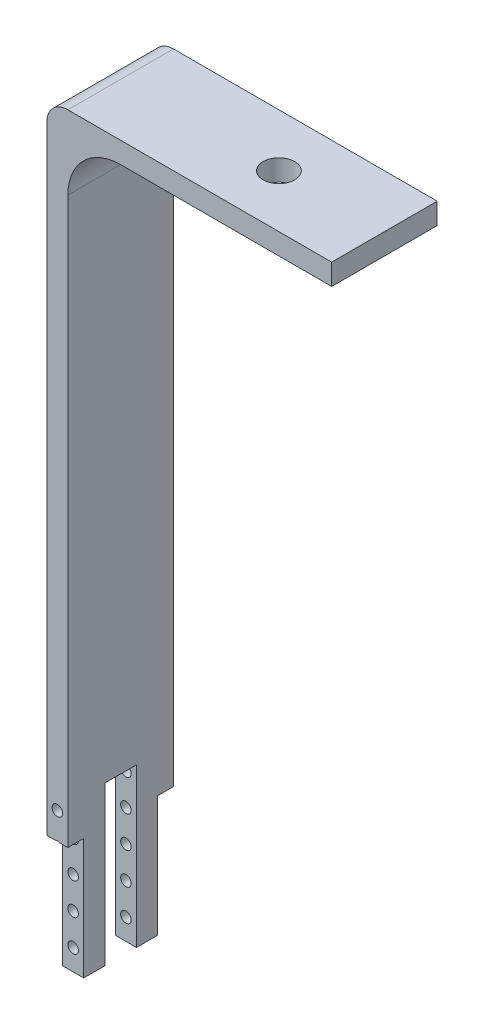
from build123d import *

# Parameters (mm, degrees)
Y_KSEKLIK_EKSTR_ZYON1_DEPTH = 10
IZIM2_W                     = 1.5
IZIM2_H                     = 11.454648232
IZIM2_W_2                   = 3
IZIM2_H_2                   = 15
KES_EKSTR_ZYON1_DEPTH       = 10
IZIM3_R                     = 0.5
KES_EKSTR_ZYON2_DEPTH       = 22
IZIM4_R                     = 1.5
KES_EKSTR_ZYON3_DEPTH       = 44
RADYUS1_R                   = 5
RADYUS2_R                   = 2


with BuildPart() as part:
    # Çizim1 → Yükseklik-Ekstrüzyon1 (new body)
    with BuildSketch(Plane.XY):
        Polygon((-4.798797212, 38.403805497), (-29.798797212, 38.403805497), (-29.798797212, -31.596194503), (-31.798797212, -31.596194503), (-31.798797212, 40.403805497), (-4.798797212, 40.403805497), align=None)
    extrude(amount=Y_KSEKLIK_EKSTR_ZYON1_DEPTH)

    # Çizim2 → Kes-Ekstrüzyon1 (cut)
    with BuildSketch(Plane(origin=(-29.798797212, 0, 0), x_dir=(0, 0, -1), z_dir=(1, 0, 0))):
        with Locations((-9.25, -25.868870387)):
            Rectangle(IZIM2_W, IZIM2_H)
        with Locations((-0.75, -25.868870387)):
            Rectangle(IZIM2_W, IZIM2_H)
        with Locations((-5, -24.096194503)):
            Rectangle(IZIM2_W_2, IZIM2_H_2)
    extrude(amount=-KES_EKSTR_ZYON1_DEPTH, mode=Mode.SUBTRACT)

    # Çizim3 → Kes-Ekstrüzyon2 (cut, symmetric)
    with BuildSketch(Plane.XY.offset(8.5)):
        with Locations((-30.798797212, -29.596194503)):
            Circle(IZIM3_R)
        with Locations((-30.798797212, -26.596194503)):
            Circle(IZIM3_R)
        with Locations((-30.798797212, -23.596194503)):
            Circle(IZIM3_R)
        with Locations((-30.798797212, -20.596194503)):
            Circle(IZIM3_R)
        with Locations((-30.798797212, -17.596194503)):
            Circle(IZIM3_R)
    extrude(amount=KES_EKSTR_ZYON2_DEPTH, both=True, mode=Mode.SUBTRACT)

    # Çizim4 → Kes-Ekstrüzyon3 (cut)
    with BuildSketch(Plane(origin=(0, 40.403805497, 0), x_dir=(1, 0, 0), z_dir=(0, 1, 0))):
        with Locations((-14.798797212, -5)):
            Circle(IZIM4_R)
    extrude(amount=-KES_EKSTR_ZYON3_DEPTH, mode=Mode.SUBTRACT)

    # Radyus1
    radyus1_edges = [part.edges().sort_by_distance(p)[0] for p in [
        (-29.798797212, 38.403805497, 5),
    ]]
    fillet(radyus1_edges, radius=RADYUS1_R)

    # Radyus2
    radyus2_edges = [part.edges().sort_by_distance(p)[0] for p in [
        (-31.798797212, 40.403805497, 5),
    ]]
    fillet(radyus2_edges, radius=RADYUS2_R)


solid = part.part
